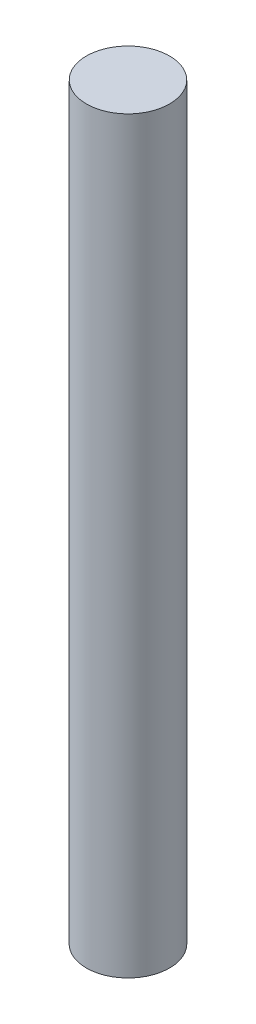
from build123d import *

# Parameters (mm, degrees)
SKETCH1_R           = 6.35
BOSS_EXTRUDE1_DEPTH = 57.15


with BuildPart() as part:
    # Sketch1 → Boss-Extrude1 (new body, symmetric)
    with BuildSketch(Plane(origin=(0, 0, 0), x_dir=(1, 0, 0), z_dir=(0, 1, 0))):
        Circle(SKETCH1_R)
    extrude(amount=BOSS_EXTRUDE1_DEPTH, both=True)


solid = part.part
